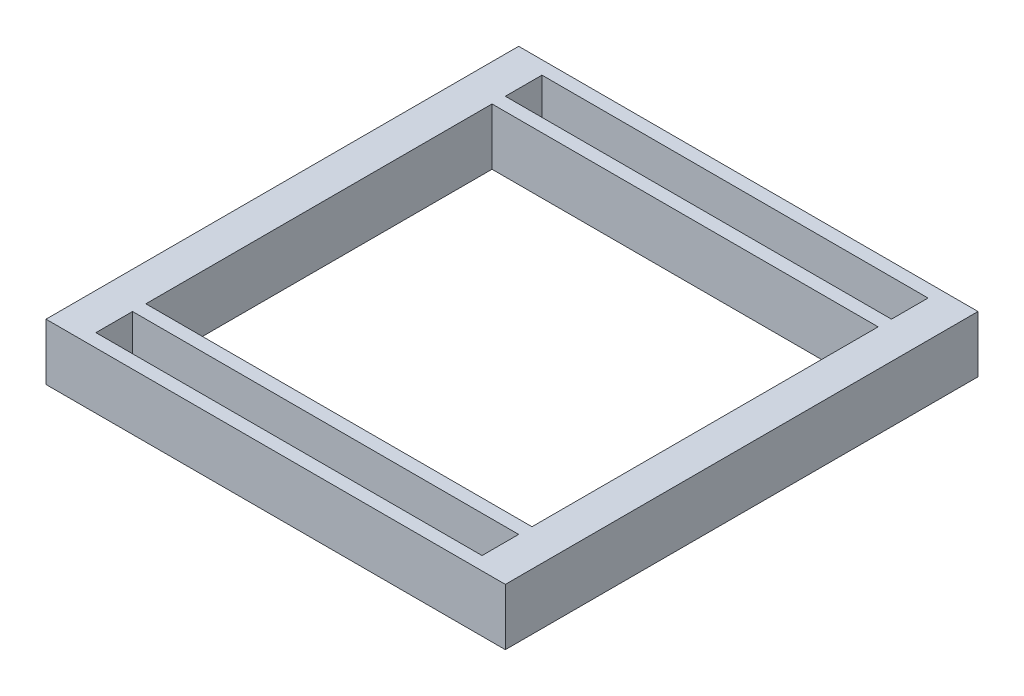
from build123d import *

# Parameters (mm, degrees)
SKETCH1_W           = 701.04
SKETCH1_H           = 721.36
SKETCH1_W_2         = 589.28
SKETCH1_H_2         = 55.88
SKETCH1_H_3         = 528.32
BOSS_EXTRUDE1_DEPTH = 86.36


with BuildPart() as part:
    # Sketch1 → Boss-Extrude1 (new body)
    with BuildSketch(Plane(origin=(0, 0, 0), x_dir=(1, 0, 0), z_dir=(0, 1, 0))):
        Rectangle(SKETCH1_W, SKETCH1_H)
        with Locations((0, 312.42)):
            Rectangle(SKETCH1_W_2, SKETCH1_H_2, mode=Mode.SUBTRACT)
        Rectangle(SKETCH1_W_2, SKETCH1_H_3, mode=Mode.SUBTRACT)
        with Locations((0, -312.42)):
            Rectangle(SKETCH1_W_2, SKETCH1_H_2, mode=Mode.SUBTRACT)
    extrude(amount=BOSS_EXTRUDE1_DEPTH)


solid = part.part
